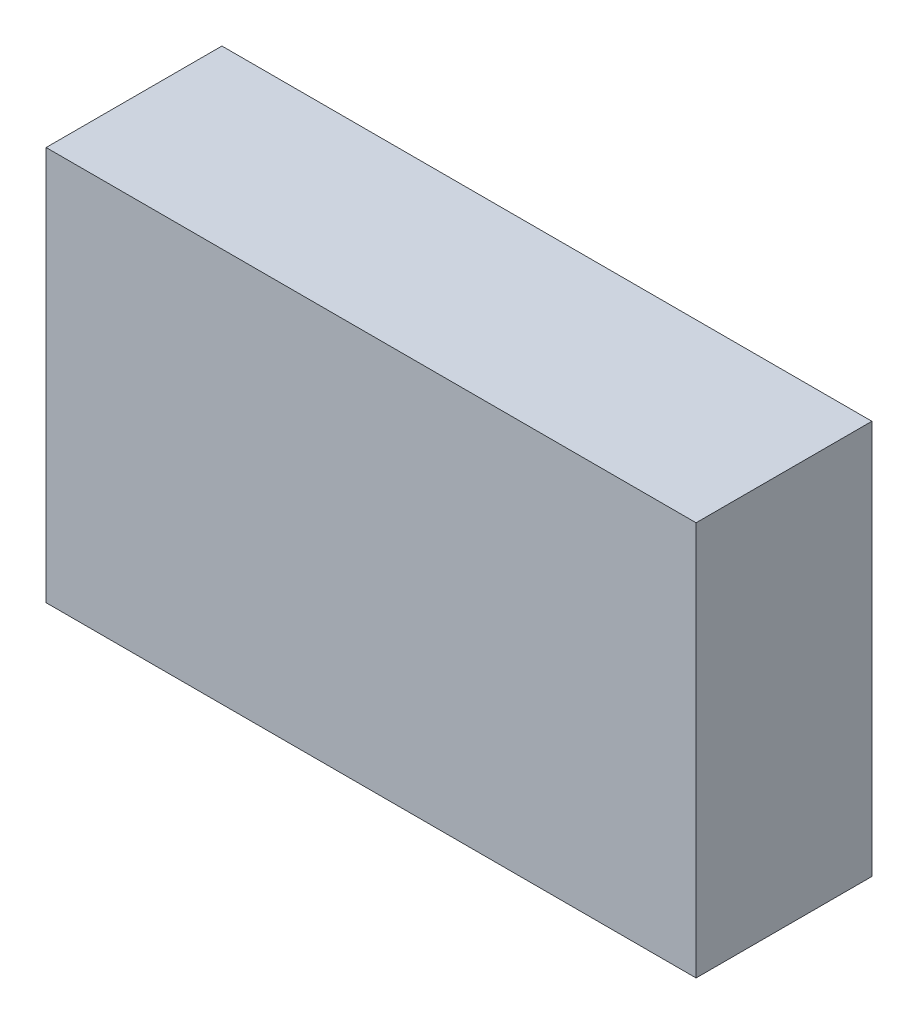
from build123d import *

# Parameters (mm, degrees)
SKETCH1_W           = 309.88
SKETCH1_H           = 187.96
BOSS_EXTRUDE1_DEPTH = 83.82


with BuildPart() as part:
    # Sketch1 → Boss-Extrude1 (new body)
    with BuildSketch(Plane.XY):
        Rectangle(SKETCH1_W, SKETCH1_H)
    extrude(amount=BOSS_EXTRUDE1_DEPTH)


solid = part.part
